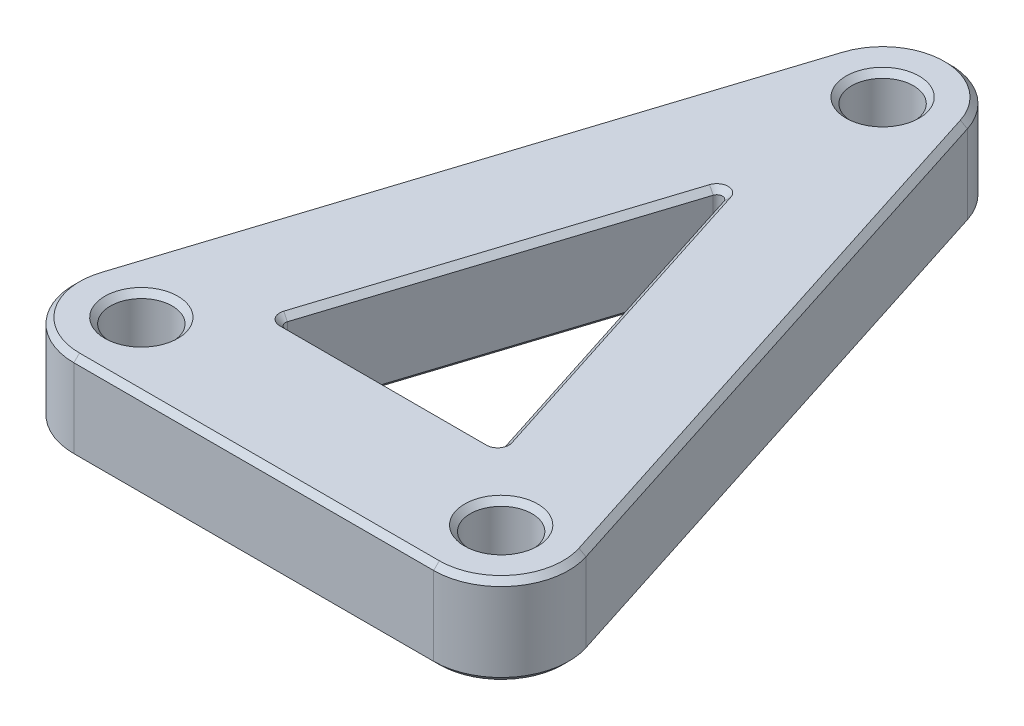
from build123d import *

# Parameters (mm, degrees)
SKETCH1_R           = 2.1828125
BOSS_EXTRUDE2_DEPTH = 6.35
CHAMFER2_SIZE       = 0.396875


with BuildPart() as part:
    # Sketch1 → Boss-Extrude2 (new body)
    with BuildSketch(Plane(origin=(0, 0, 0), x_dir=(1, 0, 0), z_dir=(0, 1, 0))):
        with BuildLine():
            Line((-4.535244397, 1.453603973), (-17.235244397, -38.170396027))
            ThreePointArc((-17.235244397, -38.170396027), (-16.547349423, -42.431010628), (-12.7, -44.3865))
            Line((-12.7, -44.3865), (12.7, -44.3865))
            ThreePointArc((12.7, -44.3865), (16.547349423, -42.431010628), (17.235244397, -38.170396027))
            Line((17.235244397, -38.170396027), (4.535244397, 1.453603973))
            ThreePointArc((4.535244397, 1.453603973), (0, 4.7625), (-4.535244397, 1.453603973))
        make_face()
        Circle(SKETCH1_R, mode=Mode.SUBTRACT)
        with Locations((12.7, -39.624)):
            Circle(SKETCH1_R, mode=Mode.SUBTRACT)
        with Locations((-12.7, -39.624)):
            Circle(SKETCH1_R, mode=Mode.SUBTRACT)
        with BuildLine():
            Line((-0.377937033, -11.581541204), (-7.67343387, -34.343491336))
            ThreePointArc((-7.67343387, -34.343491336), (-7.616109289, -34.698542552), (-7.295496837, -34.8615))
            Line((-7.295496837, -34.8615), (7.295496837, -34.8615))
            ThreePointArc((7.295496837, -34.8615), (7.616109289, -34.698542552), (7.67343387, -34.343491336))
            Line((7.67343387, -34.343491336), (0.377937033, -11.581541204))
            ThreePointArc((0.377937033, -11.581541204), (0, -11.305799869), (-0.377937033, -11.581541204))
        make_face(mode=Mode.SUBTRACT)
    extrude(amount=BOSS_EXTRUDE2_DEPTH)

    # Chamfer2
    chamfer2_edges = [part.edges().sort_by_distance(p)[0] for p in [
        (-16.547349423, 6.35, 42.431010628),
        (0, 6.35, 44.3865),
        (-2.1828125, 0, 0),
        (-2.1828125, 6.35, 0),
        (10.5171875, 0, 39.624),
        (16.547349423, 6.35, 42.431010628),
        (10.5171875, 6.35, 39.624),
        (-14.8828125, 0, 39.624),
        (10.885244397, 6.35, 18.358396027),
        (-14.8828125, 6.35, 39.624),
        (7.616109289, 0, 34.698542552),
        (4.025685452, 0, 22.96251627),
        (0, 0, 11.305799869),
        (-4.025685452, 0, 22.96251627),
        (-7.616109289, 0, 34.698542552),
        (0, 0, 34.8615),
        (7.616109289, 6.35, 34.698542552),
        (4.025685452, 6.35, 22.96251627),
        (0, 6.35, 11.305799869),
        (-4.025685452, 6.35, 22.96251627),
        (-7.616109289, 6.35, 34.698542552),
        (0, 6.35, 34.8615),
        (0, 6.35, -4.7625),
        (10.885244397, 0, 18.358396027),
        (16.547349423, 0, 42.431010628),
        (0, 0, 44.3865),
        (-16.547349423, 0, 42.431010628),
        (-10.885244397, 0, 18.358396027),
        (0, 0, -4.7625),
        (-10.885244397, 6.35, 18.358396027),
    ]]
    chamfer(chamfer2_edges, length=CHAMFER2_SIZE)


solid = part.part
